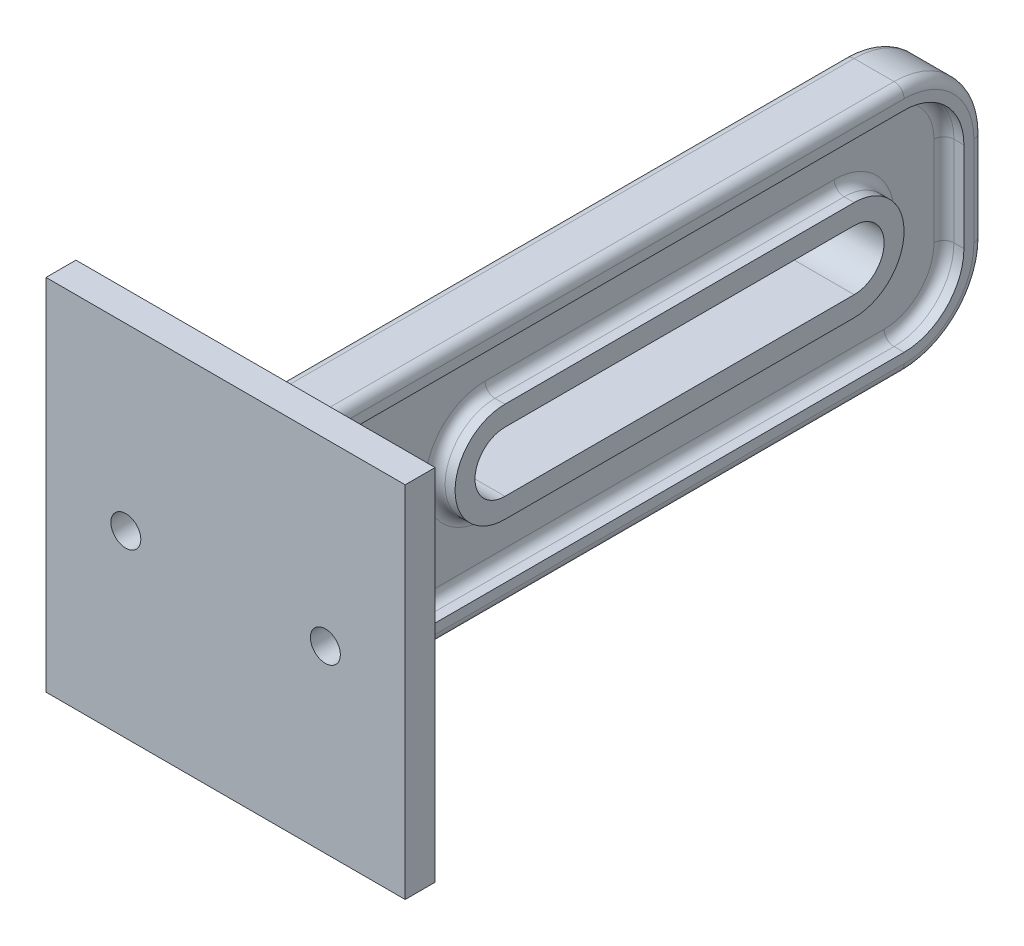
from build123d import *

# Parameters (mm, degrees)
SKETCH2_W           = 36
SKETCH2_H           = 36
BOSS_EXTRUDE1_DEPTH = 3
SKETCH3_R           = 1.5
CUT_EXTRUDE1_DEPTH  = 3
SKETCH4_W           = 6
SKETCH4_H           = 25
BOSS_EXTRUDE2_DEPTH = 70
CUT_EXTRUDE2_DEPTH  = 70
FILLET1_R           = 8
CUT_EXTRUDE3_DEPTH  = 2
FILLET2_R           = 1
FILLET3_R           = 1
FILLET4_R           = 1
FILLET5_R           = 1
FILLET6_R           = 1


with BuildPart() as part:
    # Sketch2 → Boss-Extrude1 (new body)
    with BuildSketch(Plane.XY):
        Rectangle(SKETCH2_W, SKETCH2_H)
    extrude(amount=BOSS_EXTRUDE1_DEPTH)

    # Sketch3 → Cut-Extrude1 (cut)
    with BuildSketch(Plane(origin=(0, 0, 0), x_dir=(-1, 0, 0), z_dir=(0, 0, -1))):
        with Locations((10, 0)):
            Circle(SKETCH3_R)
        with Locations((-10, 0)):
            Circle(SKETCH3_R)
    extrude(amount=-CUT_EXTRUDE1_DEPTH, mode=Mode.SUBTRACT)

    # Sketch4 → Boss-Extrude2 (add)
    with BuildSketch(Plane(origin=(0, 0, 0), x_dir=(-1, 0, 0), z_dir=(0, 0, -1))):
        Rectangle(SKETCH4_W, SKETCH4_H)
    extrude(amount=BOSS_EXTRUDE2_DEPTH)

    # Sketch5 → Cut-Extrude2 (cut)
    with BuildSketch(Plane(origin=(3, 0, 0), x_dir=(0, 0, -1), z_dir=(1, 0, 0))):
        with BuildLine():
            Line((57, -3), (22, -3))
            ThreePointArc((22, -3), (19, 0), (22, 3))
            Line((22, 3), (57, 3))
            ThreePointArc((57, 3), (60, 0), (57, -3))
        make_face()
    extrude(amount=-CUT_EXTRUDE2_DEPTH, mode=Mode.SUBTRACT)

    # Fillet1
    fillet1_edges = [part.edges().sort_by_distance(p)[0] for p in [
        (0, 12.5, -70),
        (0, -12.5, -70),
    ]]
    fillet(fillet1_edges, radius=FILLET1_R)

    # Sketch7 → Cut-Extrude3 (cut)
    with BuildSketch(Plane(origin=(3, 0, 0), x_dir=(0, 0, -1), z_dir=(1, 0, 0))):
        with BuildLine():
            Line((68, -4.5), (68, 4.5))
            ThreePointArc((68, 4.5), (66.242640687, 8.742640687), (62, 10.5))
            Line((62, 10.5), (2, 10.5))
            Line((2, 10.5), (2, -10.5))
            Line((2, -10.5), (62, -10.5))
            ThreePointArc((62, -10.5), (66.242640687, -8.742640687), (68, -4.5))
        make_face()
        with BuildLine():
            Line((57, 5), (22, 5))
            ThreePointArc((22, 5), (17, 0), (22, -5))
            Line((22, -5), (57, -5))
            ThreePointArc((57, -5), (62, 0), (57, 5))
        make_face(mode=Mode.SUBTRACT)
    cut_extrude3 = extrude(amount=-CUT_EXTRUDE3_DEPTH, mode=Mode.SUBTRACT)

    # Mirror1: Cut-Extrude3 across plane
    add(cut_extrude3.mirror(Plane(origin=(0, 0, 0), x_dir=(0, 0, 1), z_dir=(1, 0, 0))), mode=Mode.SUBTRACT)

    # Fillet2
    fillet2_edges = [part.edges().sort_by_distance(p)[0] for p in [
        (-3, 0, -70),
        (3, 0, -70),
        (3, -12.5, -31),
        (3, 12.5, -31),
        (3, -10.156854249, -67.656854249),
        (3, 10.156854249, -67.656854249),
        (-3, 12.5, -31),
        (-3, -12.5, -31),
        (-3, -10.156854249, -67.656854249),
        (-3, 10.156854249, -67.656854249),
    ]]
    fillet(fillet2_edges, radius=FILLET2_R)

    # Fillet3
    fillet3_edges = [part.edges().sort_by_distance(p)[0] for p in [
        (-1, -8.742640687, -66.242640687),
        (-1, 0, -68),
        (-1, 8.742640687, -66.242640687),
        (-1, 10.5, -32),
        (-1, -10.5, -32),
        (1, -8.742640687, -66.242640687),
        (1, -10.5, -32),
        (1, 10.5, -32),
        (1, 8.742640687, -66.242640687),
        (1, 0, -68),
    ]]
    fillet(fillet3_edges, radius=FILLET3_R)

    # Fillet4
    fillet4_edges = [part.edges().sort_by_distance(p)[0] for p in [
        (-1, 0, -62),
        (-1, 5, -39.5),
        (-1, 0, -17),
        (-1, -5, -39.5),
        (1, -5, -39.5),
        (1, 0, -62),
        (1, 5, -39.5),
        (1, 0, -17),
    ]]
    fillet(fillet4_edges, radius=FILLET4_R)

    # Fillet5
    fillet5_edges = [part.edges().sort_by_distance(p)[0] for p in [
        (-2.5, -10.5, -2),
        (-1, 0, -2),
        (-2.5, 10.5, -2),
        (-1.292893219, 10.207106781, -2),
        (-1.292893219, -10.207106781, -2),
        (1, 0, -2),
        (2.5, -10.5, -2),
        (2.5, 10.5, -2),
        (1.292893219, 10.207106781, -2),
        (1.292893219, -10.207106781, -2),
    ]]
    fillet(fillet5_edges, radius=FILLET5_R)

    # Fillet6
    fillet6_edges = [part.edges().sort_by_distance(p)[0] for p in [
        (-3, 0, 0),
        (0, -12.5, 0),
        (0, 12.5, 0),
        (3, 0, 0),
        (-2.707106781, -12.207106781, 0),
        (-2.707106781, 12.207106781, 0),
        (2.707106781, 12.207106781, 0),
        (2.707106781, -12.207106781, 0),
    ]]
    fillet(fillet6_edges, radius=FILLET6_R)


solid = part.part
